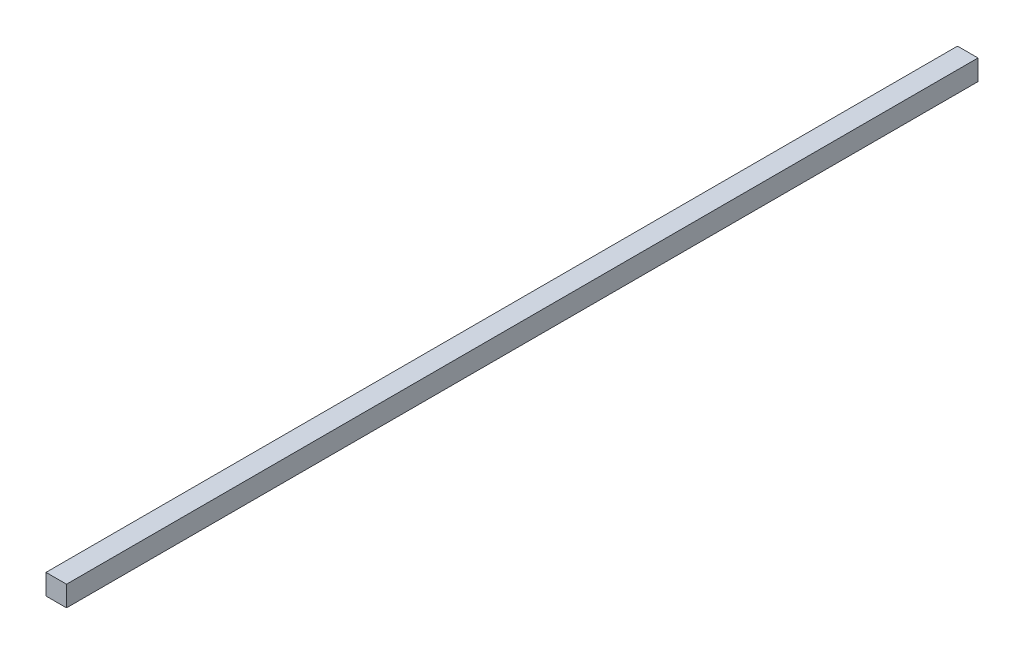
from build123d import *

# Parameters (mm, degrees)
SKETCH1_W           = 45
SKETCH1_H           = 45
BOSS_EXTRUDE1_DEPTH = 2000


with BuildPart() as part:
    # Sketch1 → Boss-Extrude1 (new body)
    with BuildSketch(Plane.XY):
        with Locations((22.5, 22.5)):
            Rectangle(SKETCH1_W, SKETCH1_H)
    extrude(amount=BOSS_EXTRUDE1_DEPTH)


solid = part.part
